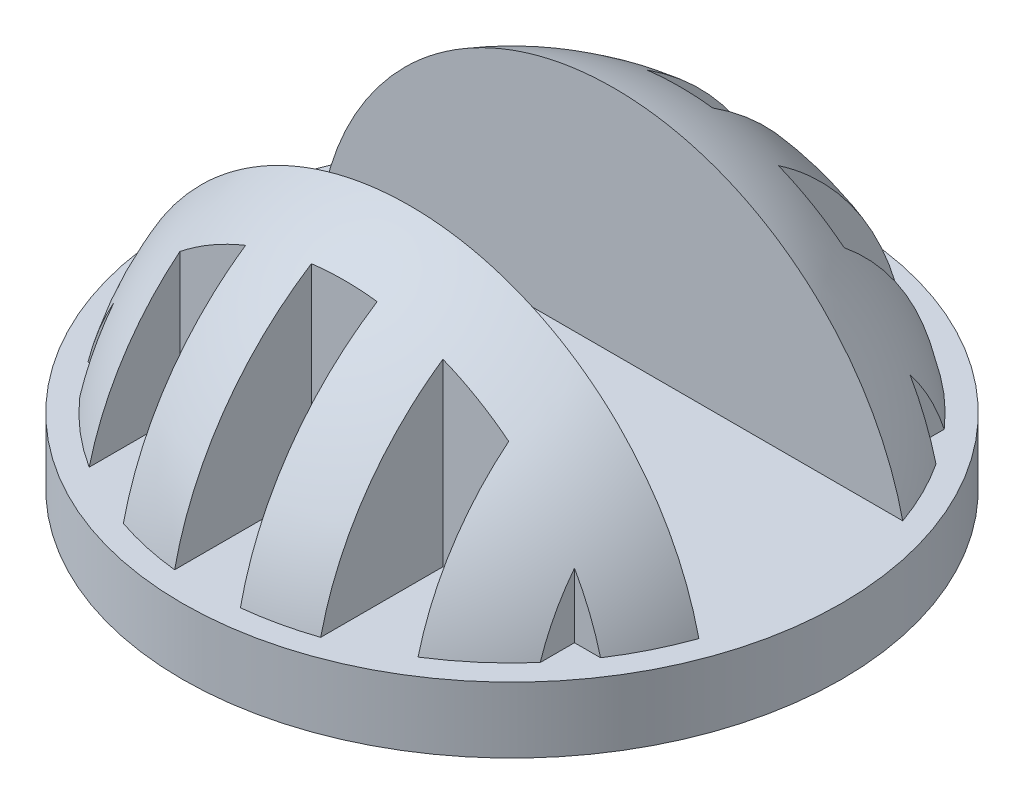
from build123d import *

# Parameters (mm, degrees)
SKETCH2_R           = 10.025
BOSS_EXTRUDE1_DEPTH = 2
SKETCH3_W           = 2
SKETCH3_H           = 15.533622691
CUT_EXTRUDE1_DEPTH  = 8.525


with BuildPart() as part:
    # Sketch1 → Revolve1 (revolve)
    with BuildSketch(Plane.XY):
        with BuildLine():
            Line((9.525, 0), (0, 0))
            Line((0, 0), (0, 9.525))
            ThreePointArc((0, 9.525), (6.735192091, 6.735192091), (9.525, 0))
        make_face()
    revolve(axis=Axis((0, 0, 0), (0, 1, 0)))

    # Sketch2 → Boss-Extrude1 (add)
    with BuildSketch(Plane.XZ):
        Circle(SKETCH2_R)
    extrude(amount=-BOSS_EXTRUDE1_DEPTH)

    # Sketch3 → Cut-Extrude1 (cut, through all)
    with BuildSketch(Plane(origin=(0, 2, 0), x_dir=(1, 0, 0), z_dir=(0, 1, 0))):
        Polygon((-9.533657483, -3.1), (9.533657483, -3.1), (10.025, -3.1), (10.025, 3.1), (9.533657483, 3.1), (-9.533657483, 3.1), (-10.025, 3.1), (-10.025, -3.1), align=None)
        with Locations((0, -12.866811346)):
            Rectangle(SKETCH3_W, SKETCH3_H)
        with Locations((0, 12.866811346)):
            Rectangle(SKETCH3_W, SKETCH3_H)
        with Locations((4, -12.866811346)):
            Rectangle(SKETCH3_W, SKETCH3_H)
        with Locations((4, 12.866811346)):
            Rectangle(SKETCH3_W, SKETCH3_H)
        with Locations((8, -12.866811346)):
            Rectangle(SKETCH3_W, SKETCH3_H)
        with Locations((8, 12.866811346)):
            Rectangle(SKETCH3_W, SKETCH3_H)
        with Locations((12, -12.866811346)):
            Rectangle(SKETCH3_W, SKETCH3_H)
        with Locations((12, 12.866811346)):
            Rectangle(SKETCH3_W, SKETCH3_H)
        with Locations((16, -12.866811346)):
            Rectangle(SKETCH3_W, SKETCH3_H)
        with Locations((16, 12.866811346)):
            Rectangle(SKETCH3_W, SKETCH3_H)
        with Locations((-4, 12.866811346)):
            Rectangle(SKETCH3_W, SKETCH3_H)
        with Locations((-4, -12.866811346)):
            Rectangle(SKETCH3_W, SKETCH3_H)
        with Locations((-8, 12.866811346)):
            Rectangle(SKETCH3_W, SKETCH3_H)
        with Locations((-8, -12.866811346)):
            Rectangle(SKETCH3_W, SKETCH3_H)
        with Locations((-12, 12.866811346)):
            Rectangle(SKETCH3_W, SKETCH3_H)
        with Locations((-12, -12.866811346)):
            Rectangle(SKETCH3_W, SKETCH3_H)
        with Locations((-16, 12.866811346)):
            Rectangle(SKETCH3_W, SKETCH3_H)
        with Locations((-16, -12.866811346)):
            Rectangle(SKETCH3_W, SKETCH3_H)
    extrude(amount=CUT_EXTRUDE1_DEPTH, mode=Mode.SUBTRACT)


solid = part.part
